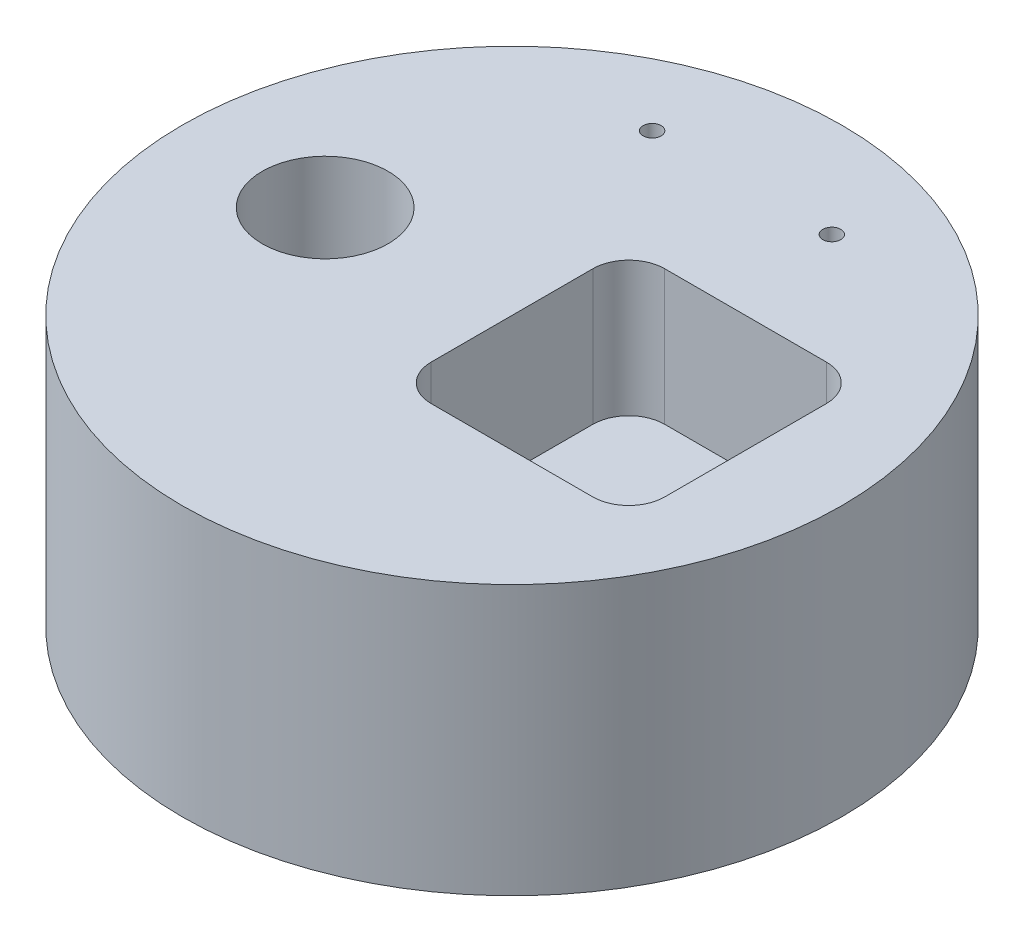
from build123d import *

# Parameters (mm, degrees)
SKETCH1_R           = 46.609
BOSS_EXTRUDE1_DEPTH = 38.1
SKETCH2_R           = 1.27
CUT_EXTRUDE1_DEPTH  = 38.1
SKETCH3_R           = 8.89
CUT_EXTRUDE2_DEPTH  = 38.1
SKETCH4_W           = 33.02
SKETCH4_H           = 33.02
CUT_EXTRUDE3_DEPTH  = 19.05
FILLET1_R           = 5.08


with BuildPart() as part:
    # Sketch1 → Boss-Extrude1 (new body)
    with BuildSketch(Plane(origin=(0, 0, 0), x_dir=(1, 0, 0), z_dir=(0, 1, 0))):
        Circle(SKETCH1_R)
    extrude(amount=BOSS_EXTRUDE1_DEPTH)

    # Sketch2 → Cut-Extrude1 (cut)
    with BuildSketch(Plane(origin=(0, 38.1, 0), x_dir=(1, 0, 0), z_dir=(0, 1, 0))):
        with Locations((12.7, 32.512)):
            Circle(SKETCH2_R)
        with Locations((-12.7, 32.512)):
            Circle(SKETCH2_R)
    extrude(amount=-CUT_EXTRUDE1_DEPTH, mode=Mode.SUBTRACT)

    # Sketch3 → Cut-Extrude2 (cut)
    with BuildSketch(Plane(origin=(0, 38.1, 0), x_dir=(1, 0, 0), z_dir=(0, 1, 0))):
        with Locations((-26.409958794, 0)):
            Circle(SKETCH3_R)
    extrude(amount=-CUT_EXTRUDE2_DEPTH, mode=Mode.SUBTRACT)

    # Sketch4 → Cut-Extrude3 (cut)
    with BuildSketch(Plane(origin=(0, 38.1, 0), x_dir=(1, 0, 0), z_dir=(0, 1, 0))):
        with Locations((16.51, 0)):
            Rectangle(SKETCH4_W, SKETCH4_H)
    extrude(amount=-CUT_EXTRUDE3_DEPTH, mode=Mode.SUBTRACT)

    # Fillet1
    fillet1_edges = [part.edges().sort_by_distance(p)[0] for p in [
        (0, 28.575, 16.51),
        (0, 28.575, -16.51),
        (33.02, 28.575, -16.51),
        (33.02, 28.575, 16.51),
    ]]
    fillet(fillet1_edges, radius=FILLET1_R)


solid = part.part
